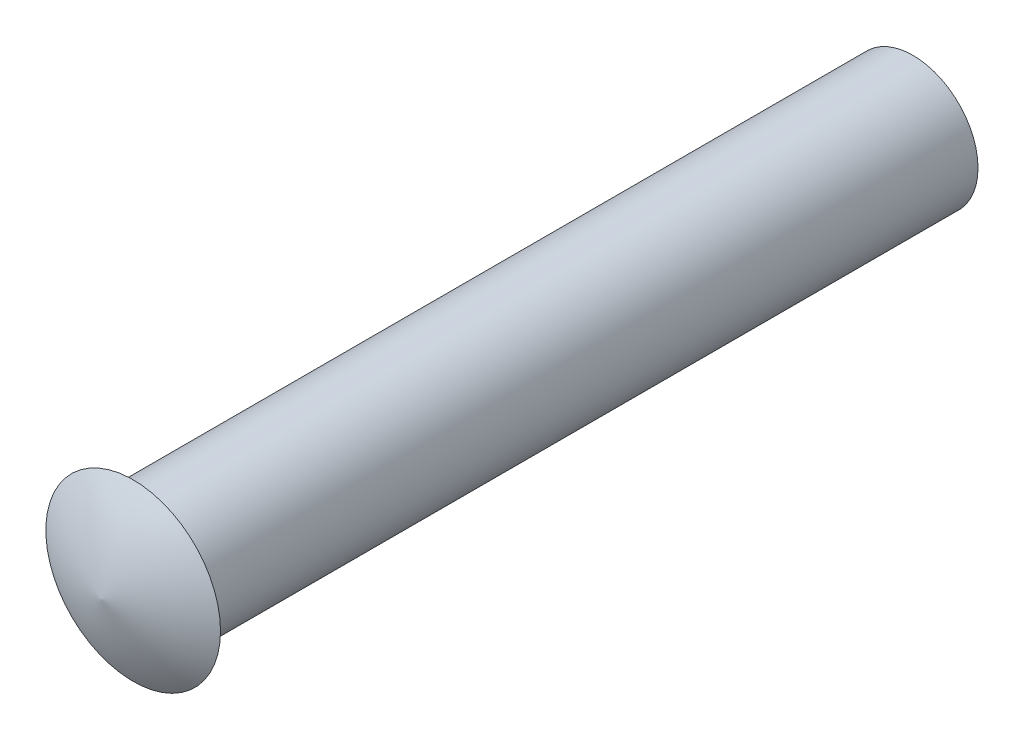
from build123d import *


with BuildPart() as part:
    # Sketch1 → Revolve1 (revolve)
    with BuildSketch(Plane(origin=(0, 0, 0), x_dir=(0, 0, -1), z_dir=(1, 0, 0))):
        with BuildLine():
            Line((0, 0), (19.8374, 0))
            Line((19.8374, 0), (19.8374, 1.5875))
            Line((19.8374, 1.5875), (0.7874, 1.5875))
            Line((0.7874, 1.5875), (0.7874, 2.1336))
            ThreePointArc((0.7874, 2.1336), (0.287016319, 1.106171358), (0, 0))
        make_face()
    revolve(axis=Axis((0, 0, 0), (0, 0, -1)))


solid = part.part
